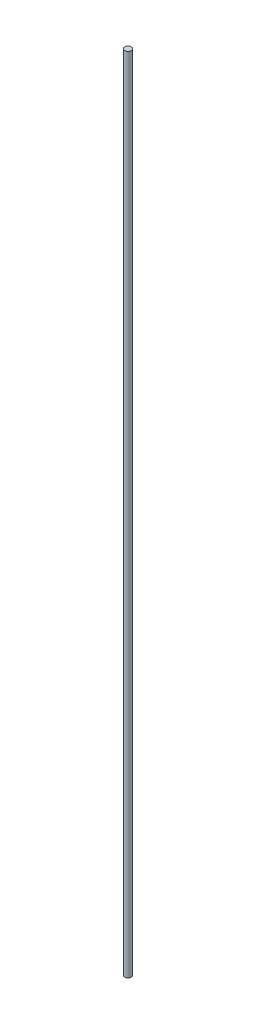
from build123d import *

# Parameters (mm, degrees)
SKETCH1_R           = 3.175
BOSS_EXTRUDE1_DEPTH = 387.35


with BuildPart() as part:
    # Sketch1 → Boss-Extrude1 (new body, symmetric)
    with BuildSketch(Plane(origin=(0, 0, 0), x_dir=(1, 0, 0), z_dir=(0, 1, 0))):
        Circle(SKETCH1_R)
    extrude(amount=BOSS_EXTRUDE1_DEPTH, both=True)


solid = part.part
